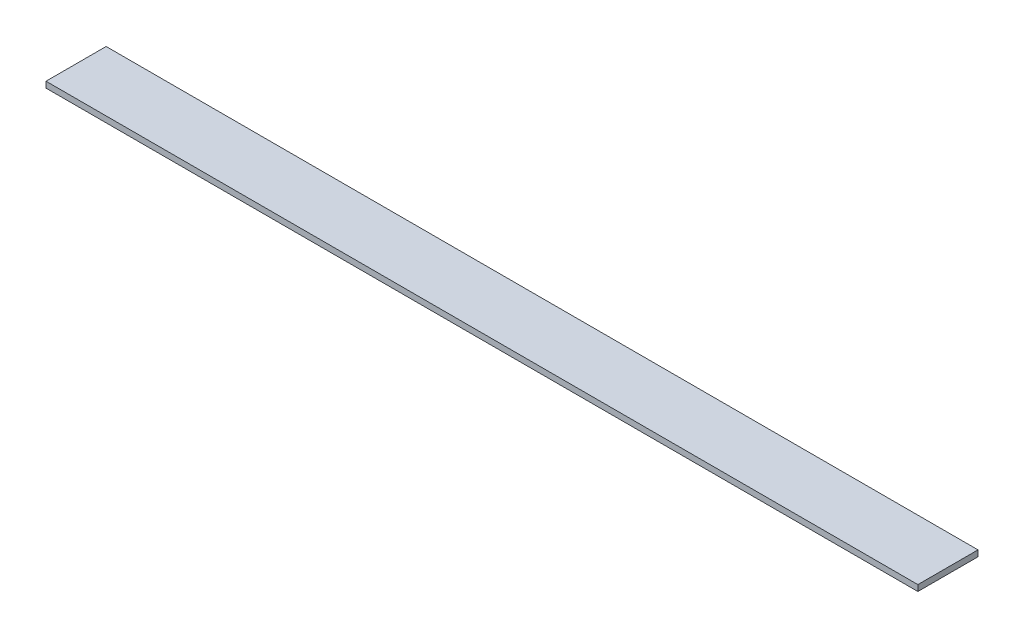
from build123d import *

# Parameters (mm, degrees)
ESQUISSE1_W      = 1450
ESQUISSE1_H      = 100
EXTRUSION1_DEPTH = 10


with BuildPart() as part:
    # Esquisse1 → Extrusion1 (new body)
    with BuildSketch(Plane(origin=(0, 0, 0), x_dir=(1, 0, 0), z_dir=(0, 1, 0))):
        with Locations((725, 50)):
            Rectangle(ESQUISSE1_W, ESQUISSE1_H)
    extrude(amount=EXTRUSION1_DEPTH)


solid = part.part
